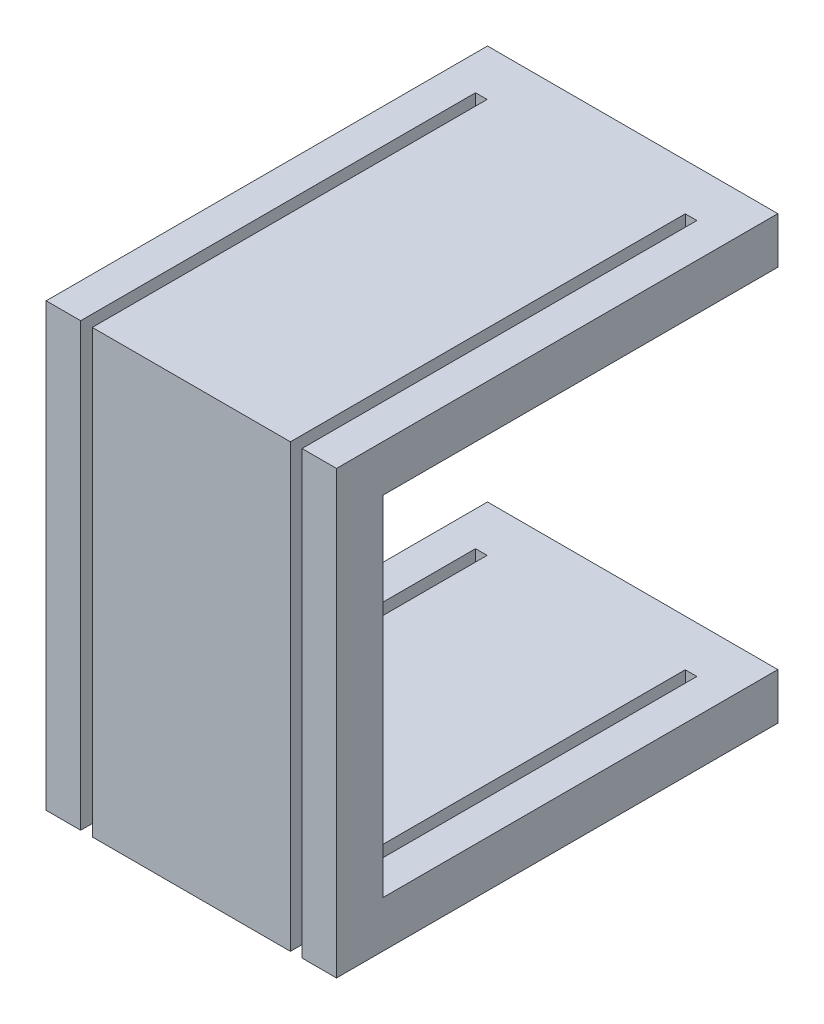
from build123d import *

# Parameters (mm, degrees)
SKETCH2_W           = 4
SKETCH2_H           = 30
BOSS_EXTRUDE1_DEPTH = 25
SKETCH3_W           = 1
SKETCH3_H           = 38
CUT_EXTRUDE1_DEPTH  = 34


with BuildPart() as part:
    # Sketch2 → Boss-Extrude1 (new body)
    with BuildSketch(Plane(origin=(0, 0, 0), x_dir=(0, 0, -1), z_dir=(1, 0, 0))):
        Rectangle(SKETCH2_W, SKETCH2_H)
        Polygon((-2, 19), (-2, 15), (2, 15), (36, 15), (36, 19), align=None)
        Polygon((2, -15), (-2, -15), (-2, -19), (36, -19), (36, -15), align=None)
    extrude(amount=BOSS_EXTRUDE1_DEPTH)

    # Sketch3 → Cut-Extrude1 (cut)
    with BuildSketch(Plane.XY.offset(2)):
        with Locations((3.469945018, 0)):
            Rectangle(SKETCH3_W, SKETCH3_H)
        with Locations((21.530054982, 0)):
            Rectangle(SKETCH3_W, SKETCH3_H)
    extrude(amount=-CUT_EXTRUDE1_DEPTH, mode=Mode.SUBTRACT)


solid = part.part
